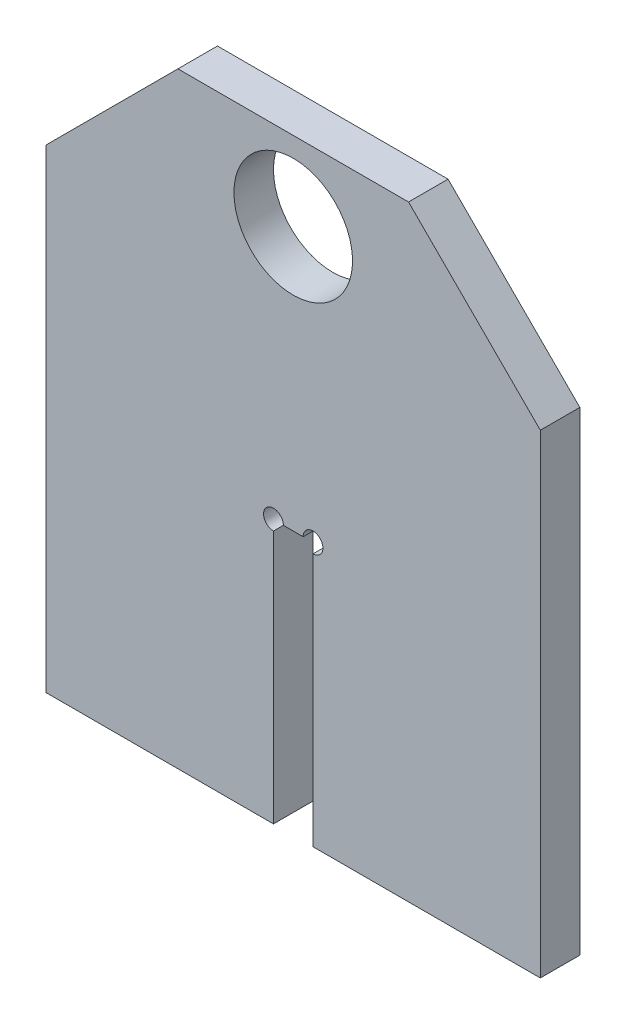
from build123d import *

# Parameters (mm, degrees)
SKETCH1_R           = 9
BOSS_EXTRUDE1_DEPTH = 6


with BuildPart() as part:
    # Sketch1 → Boss-Extrude1 (new body)
    with BuildSketch(Plane.XY):
        with BuildLine():
            Line((3, 160), (37.5, 160))
            Line((37.5, 160), (37.5, 232.000025877))
            Line((37.5, 232.000025877), (17.5, 252.000025877))
            Line((17.5, 252.000025877), (-17.5, 252.000025877))
            Line((-17.5, 252.000025877), (-37.5, 232.000025877))
            Line((-37.5, 232.000025877), (-37.5, 160))
            Line((-37.5, 160), (-3, 160))
            Line((-3, 160), (-3, 198.5))
            ThreePointArc((-3, 198.5), (-4.060660172, 201.060660172), (-1.5, 200))
            Line((-1.5, 200), (1.5, 200))
            ThreePointArc((1.5, 200), (3, 201.5), (4.5, 200))
            ThreePointArc((4.5, 200), (4.060660172, 198.939339828), (3, 198.5))
            Line((3, 198.5), (3, 160))
        make_face()
        with Locations((9.65e-05, 239.99993797)):
            Circle(SKETCH1_R, mode=Mode.SUBTRACT)
    extrude(amount=BOSS_EXTRUDE1_DEPTH)


solid = part.part
